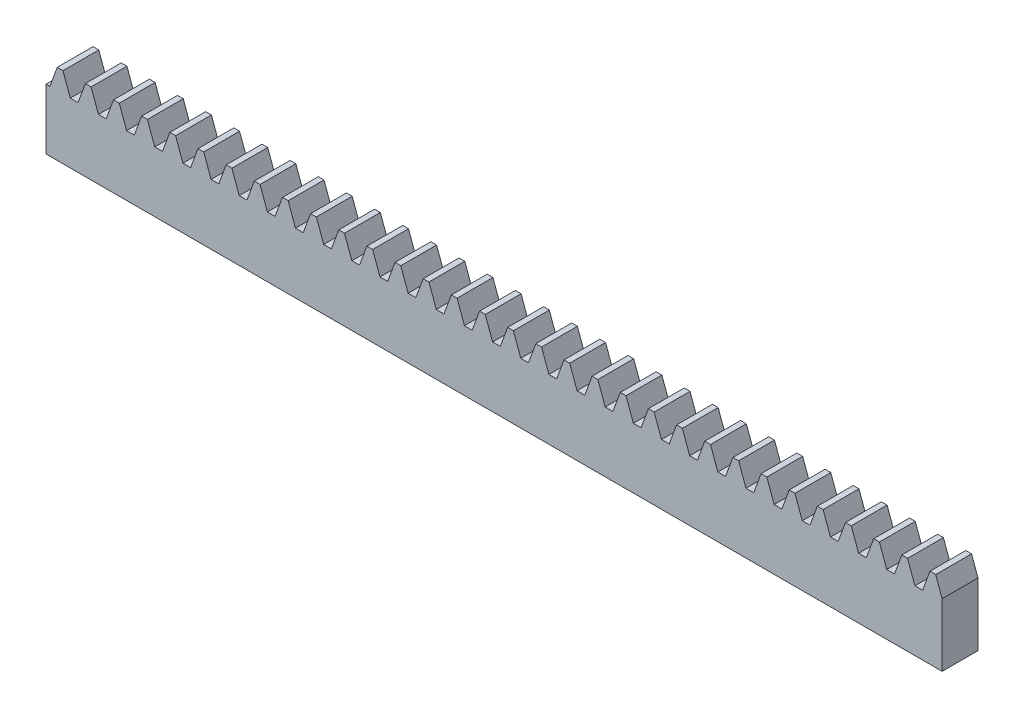
from build123d import *

# Parameters (mm, degrees)
BLANKSKE_W        = 500
BLANKSKE_H        = 45
BLANK_DEPTH       = 20
TOOTHCUTSIM_DEPTH = 503.419147724
TEETHCUTS_COUNT   = 33
TEETHCUTS_PITCH   = 15.70796325


with BuildPart() as part:
    # BlankSke → Blank (new body)
    with BuildSketch(Plane.XY):
        with Locations((250, 22.5)):
            Rectangle(BLANKSKE_W, BLANKSKE_H)
    extrude(amount=-BLANK_DEPTH)

    # TooCutSkeSim → ToothCutSim (cut, through all)
    with BuildSketch(Plane.XY):
        Polygon((2.153176848, 33.75), (-2.153176848, 33.75), (-6.257086828, 45.0254), (6.257086828, 45.0254), align=None)
    toothcutsim = extrude(amount=-TOOTHCUTSIM_DEPTH, mode=Mode.SUBTRACT)

    # TeethCuts: ToothCutSim ×33
    with Locations(*[(i * TEETHCUTS_PITCH, 0, 0) for i in range(1, TEETHCUTS_COUNT)]):
        add(toothcutsim, mode=Mode.SUBTRACT)


solid = part.part
